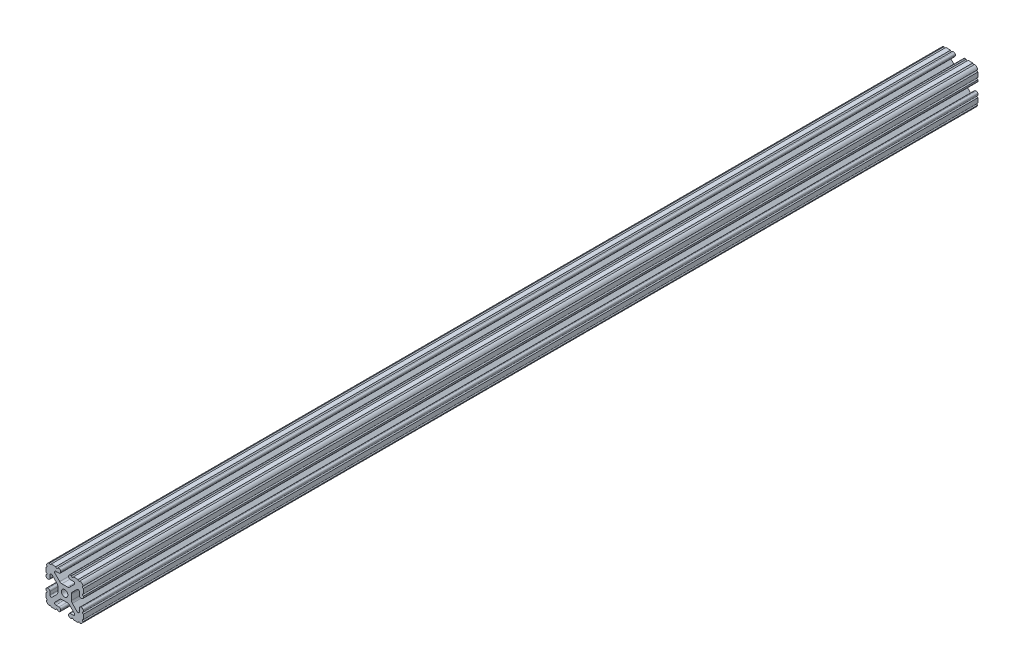
from build123d import *

# Parameters (mm, degrees)
BOSS_EXTRUDE1_DEPTH     = 457.2
SKETCH5_R               = 1.016
CUT_EXTRUDE1_DEPTH      = 458.2
CUT_EXTRUDE1_DEPTH_BACK = 458.2


with BuildPart() as part:
    # Sketch4 → Boss-Extrude1 (new body, symmetric)
    with BuildSketch(Plane.XY):
        with BuildLine():
            Line((5.7912, -19.05), (14.3002, -19.05))
            ThreePointArc((14.3002, -19.05), (17.658815789, -17.658815789), (19.05, -14.3002))
            Line((19.05, -14.3002), (19.05, -5.7912))
            ThreePointArc((19.05, -5.7912), (18.544114832, -4.569885168), (17.3228, -4.064))
            Line((17.3228, -4.064), (16.7132, -4.064))
            ThreePointArc((16.7132, -4.064), (15.491885168, -4.569885168), (14.986, -5.7912))
            Line((14.986, -5.7912), (14.986, -8.996305235))
            ThreePointArc((14.986, -8.996305235), (14.189232738, -10.188751711), (12.782646215, -9.908964256))
            Line((12.782646215, -9.908964256), (7.888897763, -5.015215804))
            ThreePointArc((7.888897763, -5.015215804), (7.219915375, -4.014012907), (6.985, -2.833013566))
            Line((6.985, -2.833013566), (6.985, 0))
            Line((6.985, 0), (3.3274, 0))
            ThreePointArc((3.3274, 0), (2.352827104, -2.352827104), (0, -3.3274))
            Line((0, -3.3274), (0, -6.985))
            Line((0, -6.985), (2.833013566, -6.985))
            ThreePointArc((2.833013566, -6.985), (4.014012907, -7.219915375), (5.015215804, -7.888897763))
            Line((5.015215804, -7.888897763), (9.908964256, -12.782646215))
            ThreePointArc((9.908964256, -12.782646215), (10.188751711, -14.189232738), (8.996305235, -14.986))
            Line((8.996305235, -14.986), (5.7912, -14.986))
            ThreePointArc((5.7912, -14.986), (4.569885168, -15.491885168), (4.064, -16.7132))
            Line((4.064, -16.7132), (4.064, -17.3228))
            ThreePointArc((4.064, -17.3228), (4.569885168, -18.544114832), (5.7912, -19.05))
        make_face()
    extrude(amount=BOSS_EXTRUDE1_DEPTH, both=True)

    # Sketch5 → Cut-Extrude1 (cut, two sides)
    with BuildSketch(Plane.XY) as cut_extrude1_sk:
        with Locations((14.739477062, -19.05)):
            Circle(SKETCH5_R)
        with Locations((7.980305235, -19.05)):
            Circle(SKETCH5_R)
        with Locations((19.05, -14.739477062)):
            Circle(SKETCH5_R)
        with Locations((19.05, -7.980305235)):
            Circle(SKETCH5_R)
    extrude(amount=CUT_EXTRUDE1_DEPTH, mode=Mode.SUBTRACT)
    extrude(cut_extrude1_sk.sketch, amount=-CUT_EXTRUDE1_DEPTH_BACK, mode=Mode.SUBTRACT)

    # Mirror1: part across plane


with BuildPart() as part_1:
    add(part.part)
    add(part.part.mirror(Plane(origin=(0, 0, 0), x_dir=(0, 0, 1), z_dir=(1, 0, 0))))

    # Mirror2: part across plane


with BuildPart() as part_2:
    add(part_1.part)
    add(part_1.part.mirror(Plane.ZX))


solid = part_2.part
